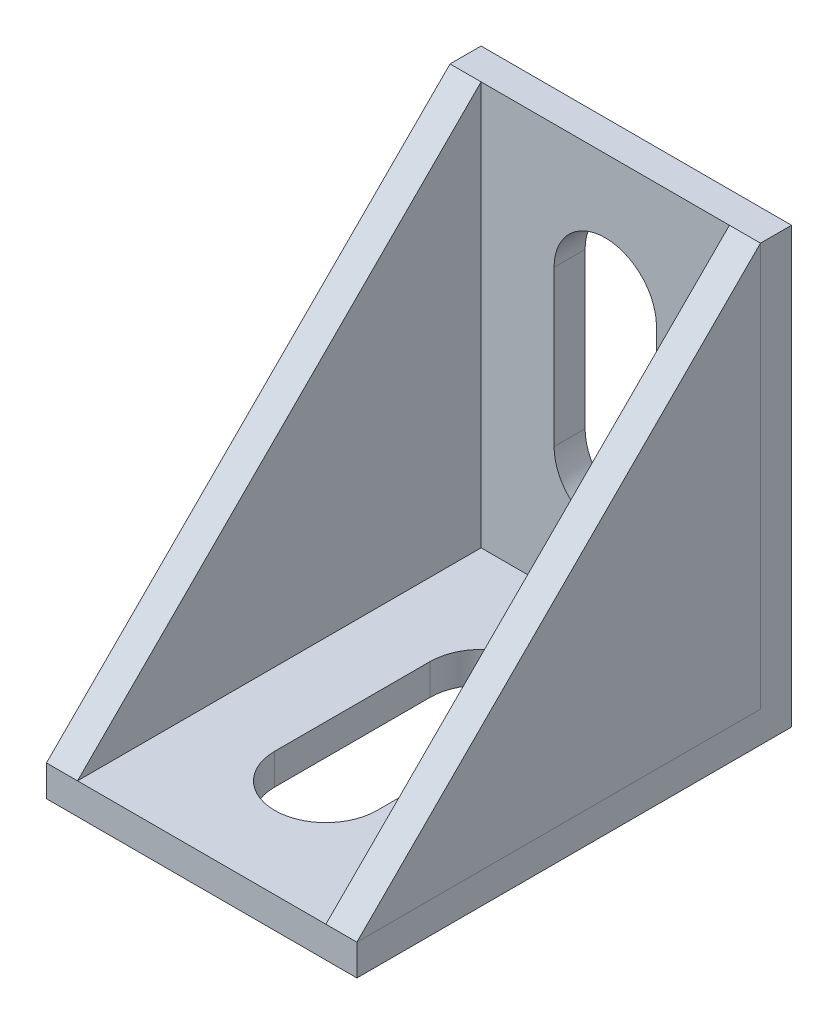
from build123d import *

# Parameters (mm, degrees)
EXTRUDE_1_DEPTH          = 20
GUSSET_2_THICKNESS       = 2
GUSSET_3_THICKNESS       = 2
CUT_EXTRUDE_1_DEPTH      = 6
CUT_EXTRUDE_1_DEPTH_BACK = 7
CUT_EXTRUDE_2_DEPTH      = 5
CUT_EXTRUDE_2_DEPTH_BACK = 3


with BuildPart() as part:
    # 草图3 → 凸台-拉伸1 (new body)
    with BuildSketch(Plane(origin=(0, 0, 0), x_dir=(0, 0, -1), z_dir=(1, 0, 0))):
        Polygon((4.462197867, 21.080677013), (4.462197867, -6.919322987), (-23.537802133, -6.919322987), (-23.537802133, -4.919322987), (2.462197867, -4.919322987), (2.462197867, 21.080677013), align=None)
    extrude(amount=EXTRUDE_1_DEPTH)

    # 草图7 → 切除-拉伸1 (cut, two sides)
    with BuildSketch(Plane(origin=(0, -4.919322987, 0), x_dir=(1, 0, 0), z_dir=(0, 1, 0))) as cut_extrude_1_sk:
        with BuildLine():
            Line((6.7, -15.537802133), (6.7, -5.537802133))
            ThreePointArc((6.7, -5.537802133), (10, -2.237802133), (13.3, -5.537802133))
            Line((13.3, -5.537802133), (13.3, -15.537802133))
            ThreePointArc((13.3, -15.537802133), (10, -18.837802133), (6.7, -15.537802133))
        make_face()
    extrude(amount=CUT_EXTRUDE_1_DEPTH, mode=Mode.SUBTRACT)
    extrude(cut_extrude_1_sk.sketch, amount=-CUT_EXTRUDE_1_DEPTH_BACK, mode=Mode.SUBTRACT)

    # 草图8 → 切除-拉伸2 (cut, two sides)
    with BuildSketch(Plane.XY.offset(-2.462197867)) as cut_extrude_2_sk:
        with BuildLine():
            Line((6.7, 3.080677013), (6.7, 13.080677013))
            ThreePointArc((6.7, 13.080677013), (10, 16.380677013), (13.3, 13.080677013))
            Line((13.3, 13.080677013), (13.3, 3.080677013))
            ThreePointArc((13.3, 3.080677013), (10, -0.219322987), (6.7, 3.080677013))
        make_face()
    extrude(amount=CUT_EXTRUDE_2_DEPTH, mode=Mode.SUBTRACT)
    extrude(cut_extrude_2_sk.sketch, amount=-CUT_EXTRUDE_2_DEPTH_BACK, mode=Mode.SUBTRACT)


with BuildPart() as body_2:
    # Gusset 2: a gusset: a plate 2.0 thick in the corner of two members, its outline drawn in place
    gusset_2_outline = Wire([Line((20, -4.919322987, -2.462197867), (20, 21.080677013, -2.462197867)), Line((20, 21.080677013, -2.462197867), (20, -4.919322987, 23.537802133)), Line((20, -4.919322987, 23.537802133), (20, -4.919322987, -2.462197867))])
    add(extrude(Face(gusset_2_outline), amount=GUSSET_2_THICKNESS, dir=(-1, 0, 0)))


with BuildPart() as body_3:
    # Gusset 3: a gusset: a plate 2.0 thick in the corner of two members, its outline drawn in place
    gusset_3_outline = Wire([Line((0, -4.919322987, -2.462197867), (0, -4.919322987, 23.537802133)), Line((0, -4.919322987, 23.537802133), (0, 21.080677013, -2.462197867)), Line((0, 21.080677013, -2.462197867), (0, -4.919322987, -2.462197867))])
    add(extrude(Face(gusset_3_outline), amount=GUSSET_3_THICKNESS, dir=(1, 0, 0)))


solid = Compound([part.part, body_2.part, body_3.part])
